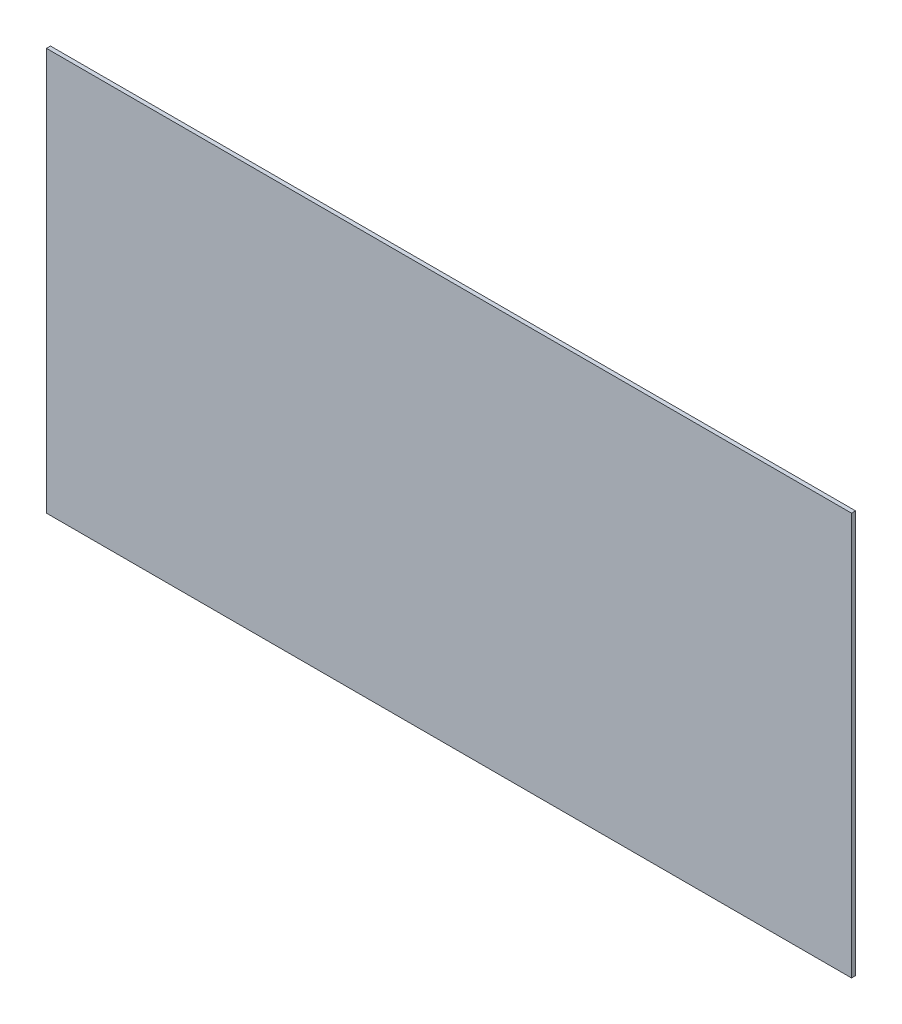
from build123d import *

# Parameters (mm, degrees)
CROQUIS1_W              = 600
CROQUIS1_H              = 300
SALIENTE_EXTRUIR1_DEPTH = 3


with BuildPart() as part:
    # Croquis1 → Saliente-Extruir1 (new body)
    with BuildSketch(Plane.XY):
        with Locations((300, 150)):
            Rectangle(CROQUIS1_W, CROQUIS1_H)
    extrude(amount=SALIENTE_EXTRUIR1_DEPTH)


solid = part.part
